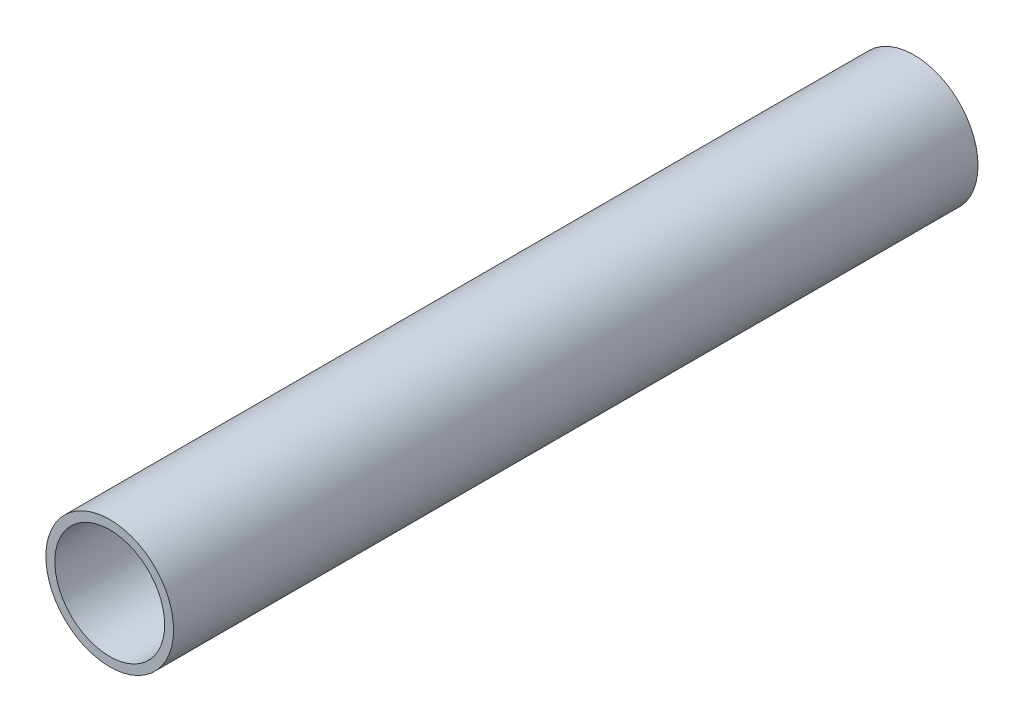
from build123d import *

# Parameters (mm, degrees)
SKETCH1_R           = 6.35
SKETCH1_R_2         = 5.461
BOSS_EXTRUDE1_DEPTH = 80


with BuildPart() as part:
    # Sketch1 → Boss-Extrude1 (new body)
    with BuildSketch(Plane.XY):
        Circle(SKETCH1_R)
        Circle(SKETCH1_R_2, mode=Mode.SUBTRACT)
    extrude(amount=BOSS_EXTRUDE1_DEPTH)


solid = part.part
